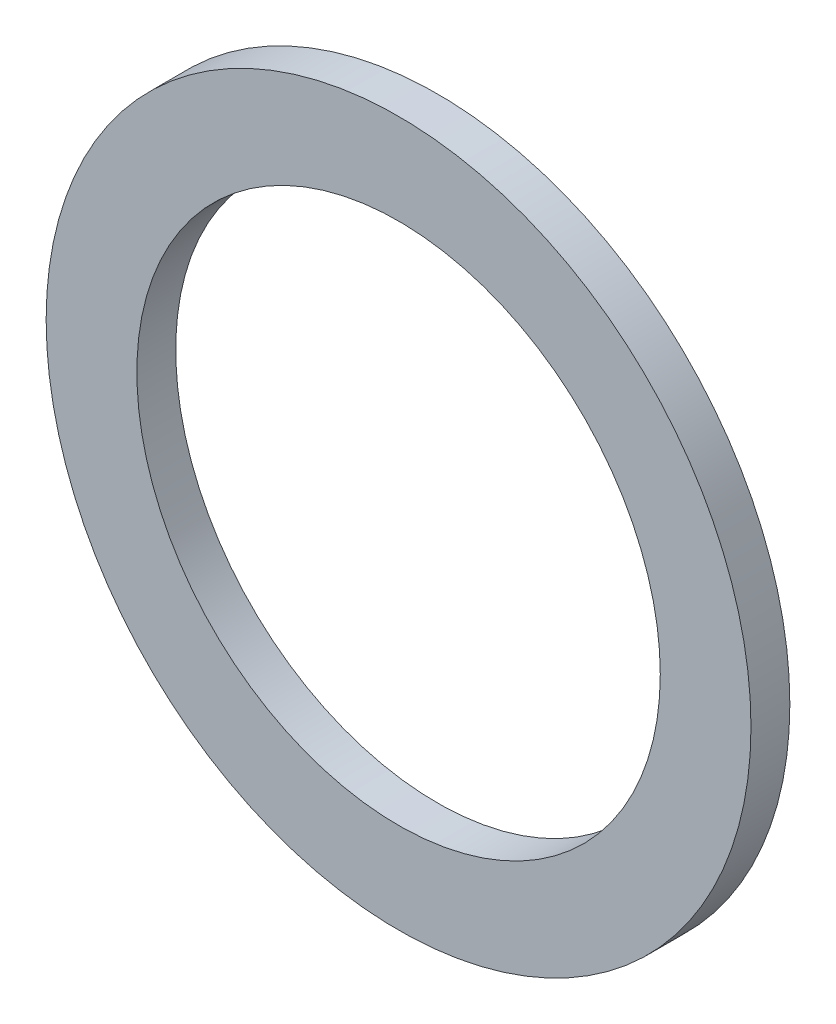
from build123d import *

# Parameters (mm, degrees)
SKETCH1_R           = 13.6
BOSS_EXTRUDE1_DEPTH = 1.5
SKETCH2_R           = 10.1
CUT_EXTRUDE1_DEPTH  = 1.5


with BuildPart() as part:
    # Sketch1 → Boss-Extrude1 (new body)
    with BuildSketch(Plane.XY):
        Circle(SKETCH1_R)
    extrude(amount=BOSS_EXTRUDE1_DEPTH)

    # Sketch2 → Cut-Extrude1 (cut)
    with BuildSketch(Plane.XY.offset(1.5)):
        Circle(SKETCH2_R)
    extrude(amount=-CUT_EXTRUDE1_DEPTH, mode=Mode.SUBTRACT)


solid = part.part
